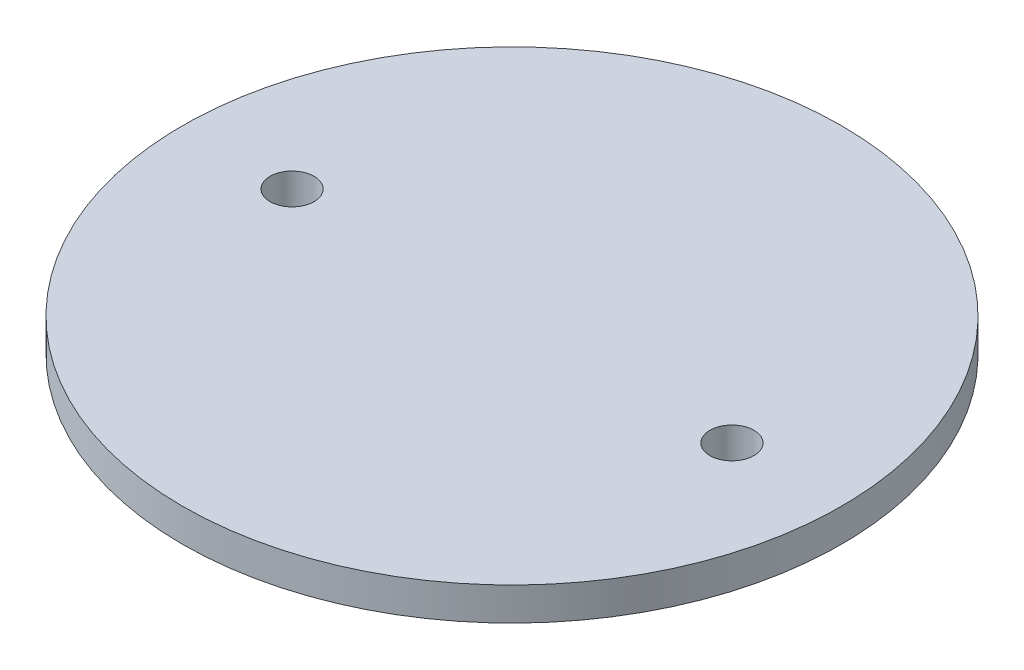
from build123d import *

# Parameters (mm, degrees)
SKETCH1_R           = 47.575
BOSS_EXTRUDE1_DEPTH = 4.7625
SKETCH2_R           = 3.175
CUT_EXTRUDE1_DEPTH  = 5.7625


with BuildPart() as part:
    # Sketch1 → Boss-Extrude1 (new body)
    with BuildSketch(Plane(origin=(0, 0, 0), x_dir=(1, 0, 0), z_dir=(0, 1, 0))):
        Circle(SKETCH1_R)
    extrude(amount=BOSS_EXTRUDE1_DEPTH)

    # Sketch2 → Cut-Extrude1 (cut, through all)
    with BuildSketch(Plane(origin=(0, 4.7625, 0), x_dir=(1, 0, 0), z_dir=(0, 1, 0))):
        with Locations((31.75, 0)):
            Circle(SKETCH2_R)
        with Locations((-31.75, 0)):
            Circle(SKETCH2_R)
    extrude(amount=-CUT_EXTRUDE1_DEPTH, mode=Mode.SUBTRACT)


solid = part.part
